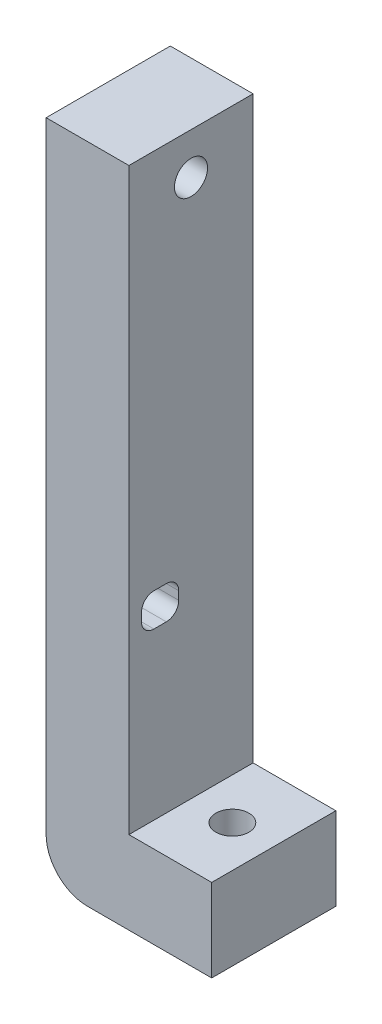
from build123d import *

# Parameters (mm, degrees)
BOSS_EXTRUDE1_DEPTH = 15
FILLET1_R           = 5
SKETCH2_W           = 10
SKETCH2_H           = 15
BOSS_EXTRUDE2_DEPTH = 40
SKETCH3_R           = 2
CUT_EXTRUDE1_DEPTH  = 81
CUT_EXTRUDE2_DEPTH  = 11
SKETCH5_R           = 2
CUT_EXTRUDE3_DEPTH  = 21


with BuildPart() as part:
    # Sketch1 → Boss-Extrude1 (new body)
    with BuildSketch(Plane.XY):
        Polygon((0, 20), (0, -10), (10, -10), (10, -20), (-10, -20), (-10, 20), align=None)
    extrude(amount=BOSS_EXTRUDE1_DEPTH)

    # Fillet1
    fillet1_edges = [part.edges().sort_by_distance(p)[0] for p in [
        (-10, -20, 7.5),
    ]]
    fillet(fillet1_edges, radius=FILLET1_R)

    # Sketch2 → Boss-Extrude2 (add)
    with BuildSketch(Plane(origin=(0, 20, 0), x_dir=(1, 0, 0), z_dir=(0, 1, 0))):
        with Locations((-5, -7.5)):
            Rectangle(SKETCH2_W, SKETCH2_H)
    extrude(amount=BOSS_EXTRUDE2_DEPTH)

    # Sketch3 → Cut-Extrude1 (cut, through all)
    with BuildSketch(Plane.XZ.offset(20)):
        with Locations((5, 7.5)):
            Circle(SKETCH3_R)
    extrude(amount=-CUT_EXTRUDE1_DEPTH, mode=Mode.SUBTRACT)

    # Sketch4 → Cut-Extrude2 (cut, through all)
    with BuildSketch(Plane(origin=(0, 0, 0), x_dir=(0, 0, -1), z_dir=(1, 0, 0))):
        with BuildLine():
            Line((-10.48, 10), (-11.98, 10))
            ThreePointArc((-11.98, 10), (-13.040660172, 10.439339828), (-13.48, 11.5))
            Line((-13.48, 11.5), (-13.48, 12.5))
            ThreePointArc((-13.48, 12.5), (-13.040660172, 13.560660172), (-11.98, 14))
            Line((-11.98, 14), (-10.48, 14))
            ThreePointArc((-10.48, 14), (-9.419339828, 13.560660172), (-8.98, 12.5))
            Line((-8.98, 12.5), (-8.98, 11.5))
            ThreePointArc((-8.98, 11.5), (-9.419339828, 10.439339828), (-10.48, 10))
        make_face()
    extrude(amount=-CUT_EXTRUDE2_DEPTH, mode=Mode.SUBTRACT)

    # Sketch5 → Cut-Extrude3 (cut, through all)
    with BuildSketch(Plane.ZY.offset(10)):
        with Locations((7.5, 55)):
            Circle(SKETCH5_R)
    extrude(amount=-CUT_EXTRUDE3_DEPTH, mode=Mode.SUBTRACT)


solid = part.part
